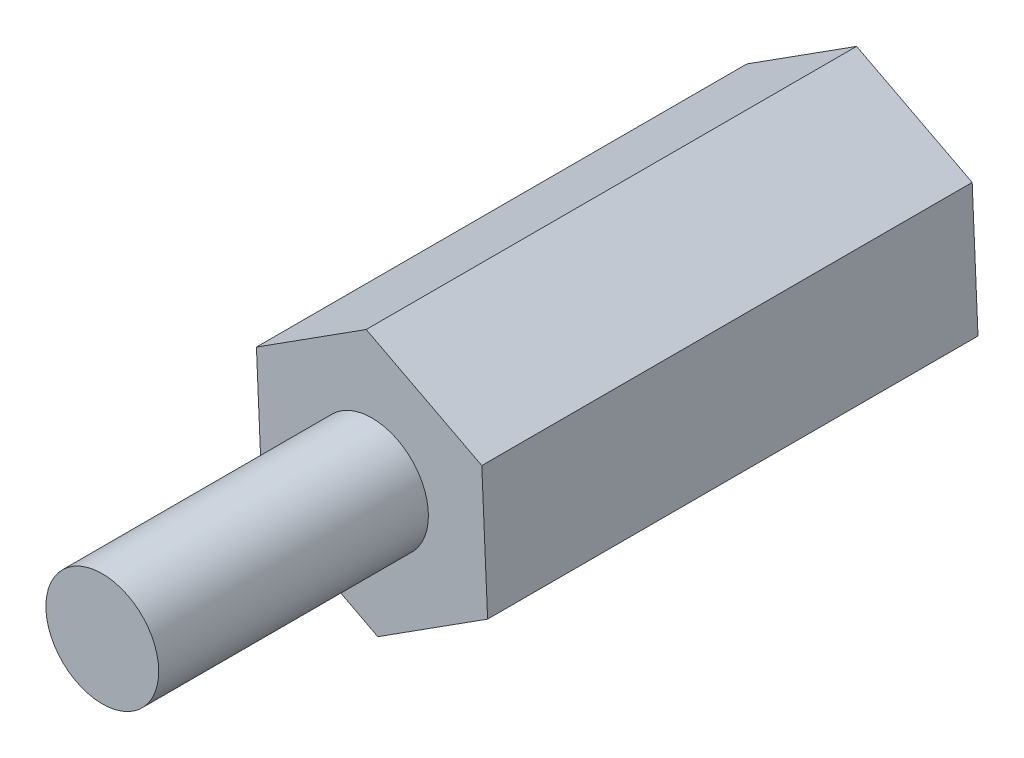
from build123d import *

# Parameters (mm, degrees)
SKETCH1_R           = 1.15
BOSS_EXTRUDE1_DEPTH = 10
SKETCH3_R           = 1.15
BOSS_EXTRUDE2_DEPTH = 5.5


with BuildPart() as part:
    # Sketch1 → Boss-Extrude1 (new body)
    with BuildSketch(Plane.XY):
        Polygon((2.357022055, -1.223838375), (2.23838615, 1.429321789), (-0.118635905, 2.653160164), (-2.357022055, 1.223838375), (-2.23838615, -1.429321789), (0.118635905, -2.653160164), align=None)
        Circle(SKETCH1_R, mode=Mode.SUBTRACT)
    extrude(amount=BOSS_EXTRUDE1_DEPTH)


with BuildPart() as body_2:
    # Sketch3 → Boss-Extrude2 (new body)
    with BuildSketch(Plane.XY.offset(10)):
        Circle(SKETCH3_R)
    extrude(amount=BOSS_EXTRUDE2_DEPTH)


solid = Compound([part.part, body_2.part])
